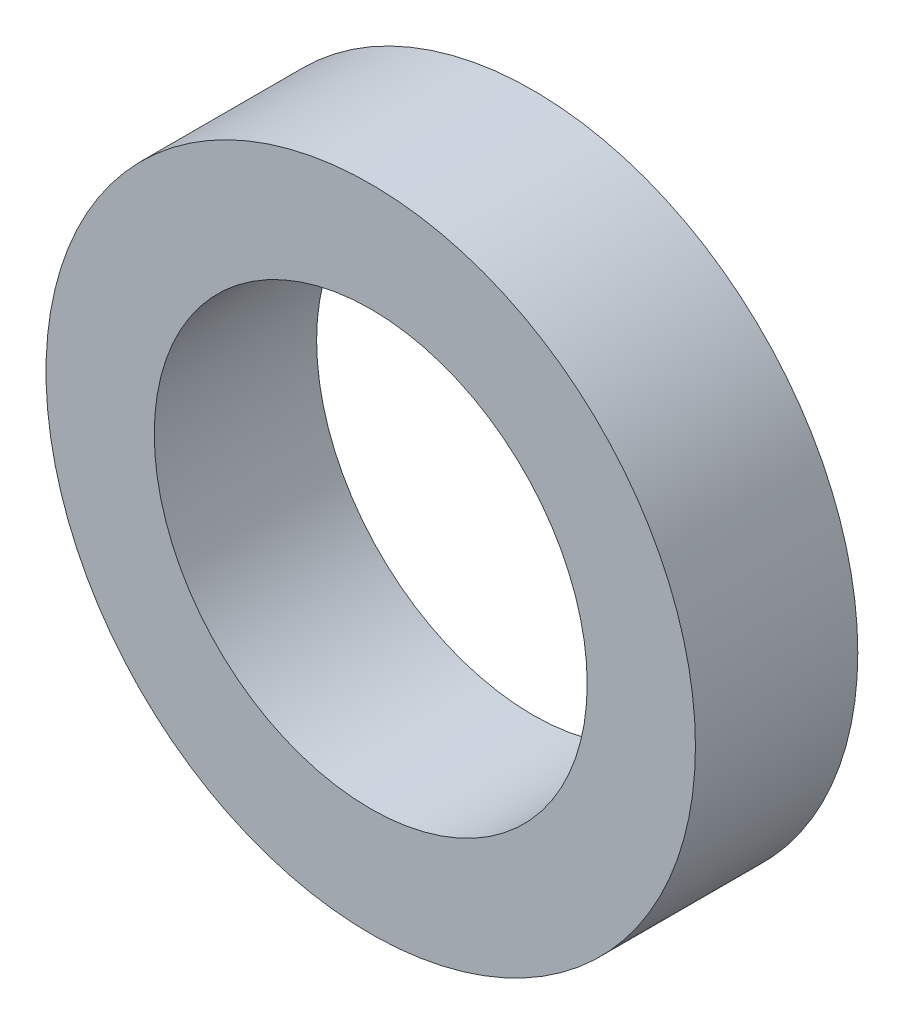
from build123d import *

# Parameters (mm, degrees)
SKETCH1_R           = 6
SKETCH1_R_2         = 4
BOSS_EXTRUDE1_DEPTH = 3


with BuildPart() as part:
    # Sketch1 → Boss-Extrude1 (new body)
    with BuildSketch(Plane.XY):
        Circle(SKETCH1_R)
        Circle(SKETCH1_R_2, mode=Mode.SUBTRACT)
    extrude(amount=BOSS_EXTRUDE1_DEPTH)


solid = part.part
